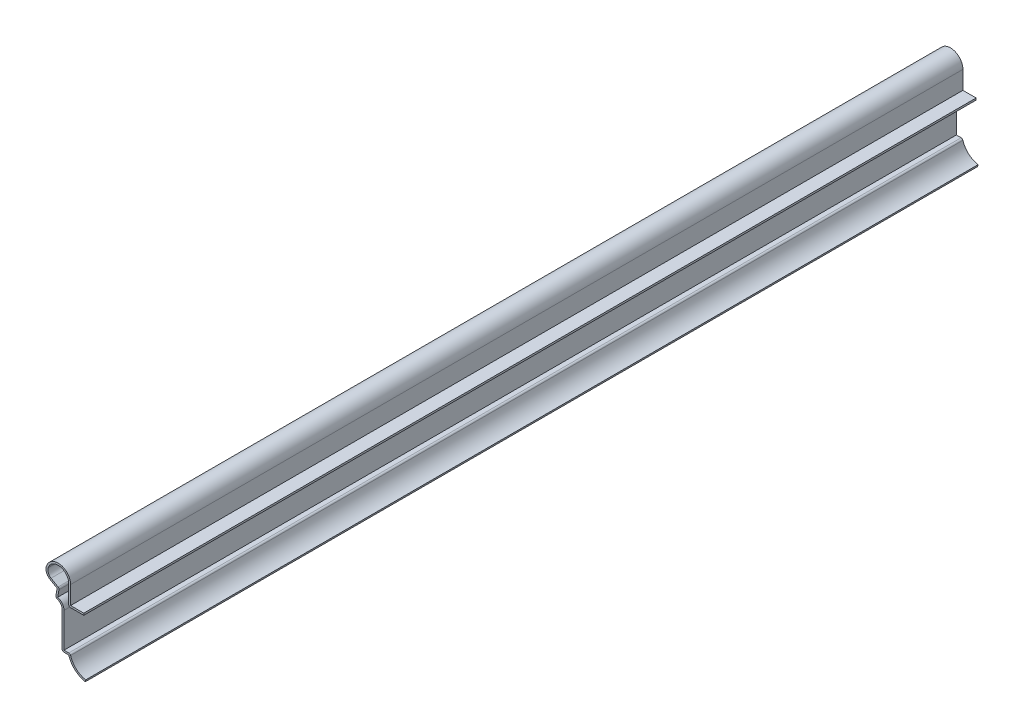
from build123d import *

# Parameters (mm, degrees)
EXTRUDE_THIN1_DEPTH = 428.625
FILLET1_R           = 0.889


with BuildPart() as part:
    # Sketch1 → Extrude-Thin1 (new body)
    with BuildSketch(Plane.XY):
        with BuildLine():
            ThreePointArc((0, 0), (4.964730566, 2.465229927), (7.9375, 7.14375))
            Line((7.9375, 7.14375), (11.1125, 7.14375))
            Line((11.1125, 7.14375), (11.1125, 24.60625))
            ThreePointArc((11.1125, 24.60625), (12.04243597, 26.85131403), (14.2875, 27.78125))
            Line((14.2875, 27.78125), (13.517722525, 32.146875))
            Line((13.517722525, 32.146875), (16.898645987, 34.098852071))
            ThreePointArc((16.898645987, 34.098852071), (18.624416275, 36.126706761), (18.680023291, 38.788921177))
            ThreePointArc((18.680023291, 38.788921177), (12.079369103, 42.78588283), (7.078269835, 36.909375))
            Line((7.078269835, 36.909375), (7.078269835, 28.178125))
            Line((7.078269835, 28.178125), (0.728269835, 28.178125))
            Line((0.728269835, 28.178125), (0.728269835, 27.289125))
            Line((0.728269835, 27.289125), (7.967269835, 27.289125))
            Line((7.967269835, 27.289125), (7.967269835, 36.909375))
            ThreePointArc((7.967269835, 36.909375), (12.221538279, 41.908324327), (17.836494775, 38.508242281))
            ThreePointArc((17.836494775, 38.508242281), (17.79334373, 36.442363895), (16.454145987, 34.868748655))
            Line((16.454145987, 34.868748655), (12.534135133, 32.605529333))
            Line((12.534135133, 32.605529333), (13.251696834, 28.536034702))
            ThreePointArc((13.251696834, 28.536034702), (11.068369678, 27.086833796), (10.2235, 24.60625))
            Line((10.2235, 24.60625), (10.2235, 8.03275))
            Line((10.2235, 8.03275), (7.254256557, 8.03275))
            ThreePointArc((7.254256557, 8.03275), (4.608977552, 3.348689722), (-0.166979013, 0.873177536))
            Line((-0.166979013, 0.873177536), (0, 0))
        make_face()
    extrude(amount=-EXTRUDE_THIN1_DEPTH)

    # Fillet1
    fillet1_edges = [part.edges().sort_by_distance(p)[0] for p in [
        (14.2875, 27.78125, -214.3125),
        (11.1125, 7.14375, -214.3125),
        (7.254256557, 8.03275, -214.3125),
        (12.534135133, 32.605529333, -214.3125),
        (7.967269835, 27.289125, -214.3125),
    ]]
    fillet(fillet1_edges, radius=FILLET1_R)


with BuildPart() as body_2:
    # Mirror1: mirrored copy
    add(part.part.mirror(Plane(origin=(0.728269835, 27.289125, -428.625), x_dir=(0, 0, 1), z_dir=(1, 0, 0))))


solid = body_2.part
